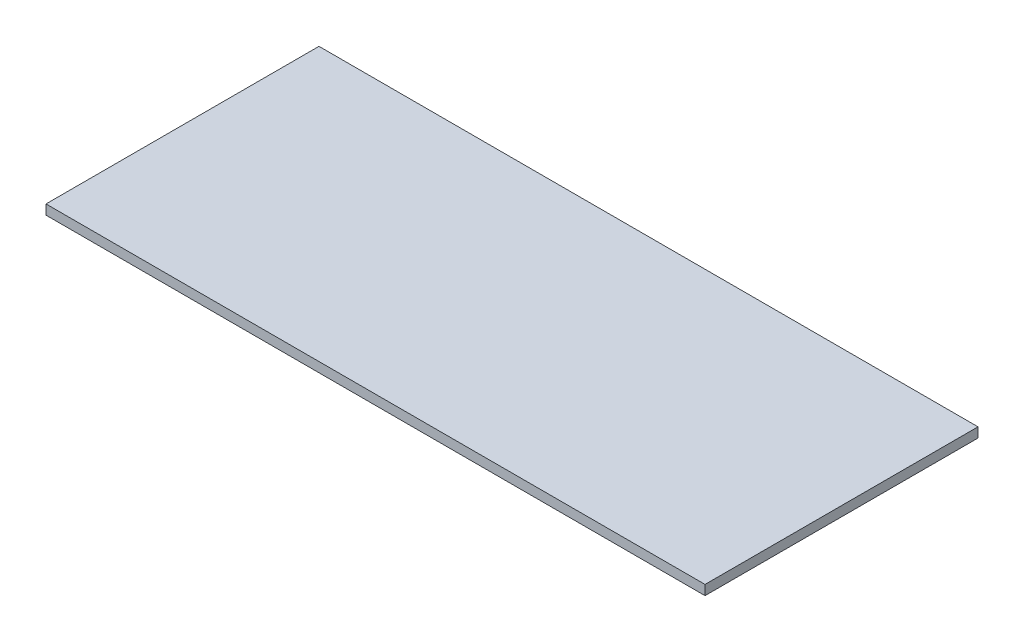
from build123d import *

# Parameters (mm, degrees)
SKETCH1_W           = 429.26
SKETCH1_H           = 177.8
BOSS_EXTRUDE1_DEPTH = 6.35


with BuildPart() as part:
    # Sketch1 → Boss-Extrude1 (new body)
    with BuildSketch(Plane(origin=(0, 0, 0), x_dir=(1, 0, 0), z_dir=(0, 1, 0))):
        with Locations((214.63, 88.9)):
            Rectangle(SKETCH1_W, SKETCH1_H)
    extrude(amount=BOSS_EXTRUDE1_DEPTH)


solid = part.part
